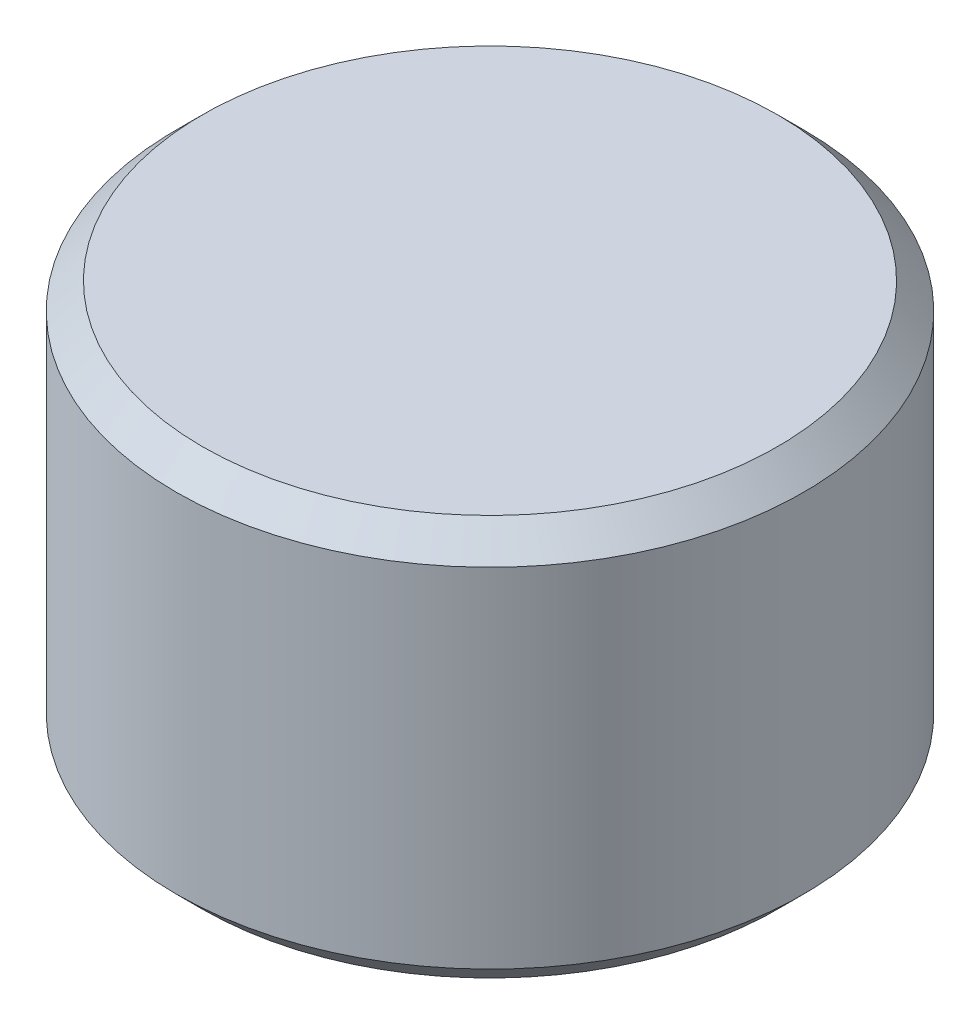
from build123d import *

# Parameters (mm, degrees)
SKETCH1_R           = 1193.8
BOSS_EXTRUDE1_DEPTH = 1524
CHAMFER1_SIZE       = 100
CHAMFER2_SIZE       = 100


with BuildPart() as part:
    # Sketch1 → Boss-Extrude1 (new body)
    with BuildSketch(Plane(origin=(0, 0, 0), x_dir=(1, 0, 0), z_dir=(0, 1, 0))):
        Circle(SKETCH1_R)
    extrude(amount=BOSS_EXTRUDE1_DEPTH)

    # Chamfer1
    chamfer1_edges = [part.edges().sort_by_distance(p)[0] for p in [
        (-1193.8, 1524, 0),
    ]]
    chamfer(chamfer1_edges, length=CHAMFER1_SIZE)

    # Chamfer2
    chamfer2_edges = [part.edges().sort_by_distance(p)[0] for p in [
        (-1193.8, 0, 0),
    ]]
    chamfer(chamfer2_edges, length=CHAMFER2_SIZE)


solid = part.part
